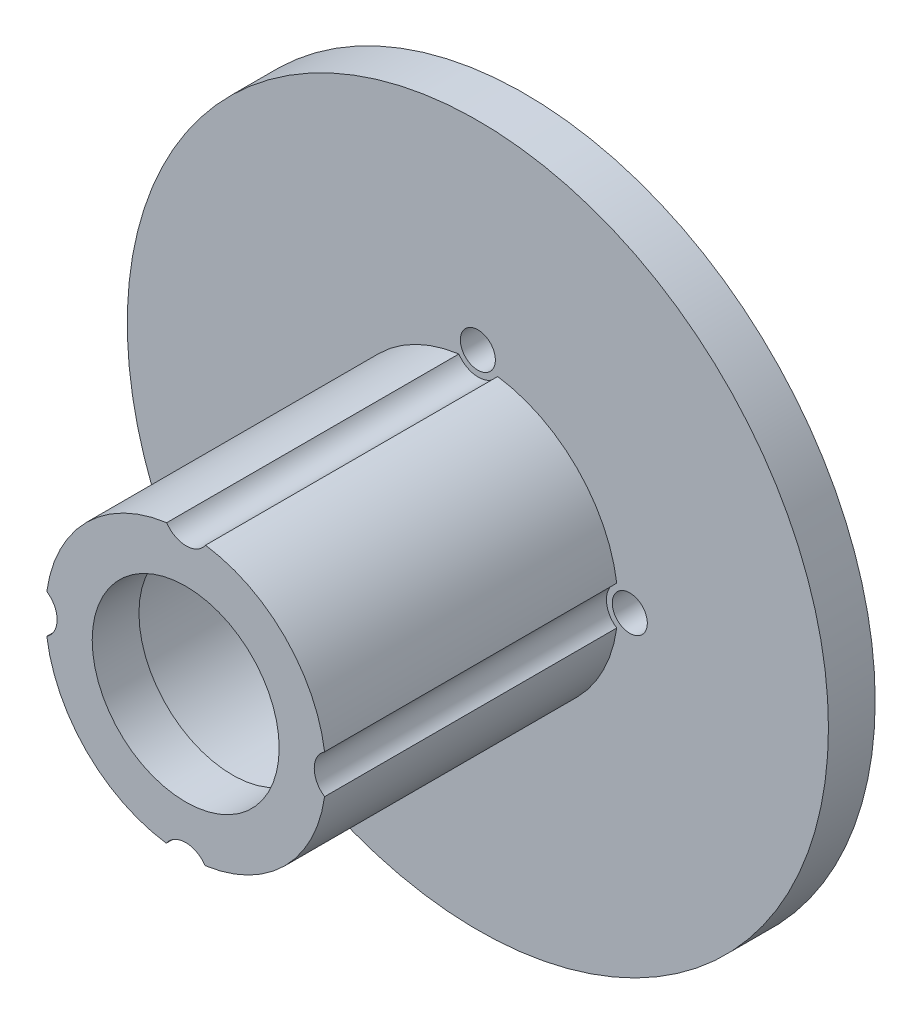
from build123d import *

# Parameters (mm, degrees)
SKETCH2_R           = 30
BOSS_EXTRUDE1_DEPTH = 4
SKETCH3_R           = 12
BOSS_EXTRUDE2_DEPTH = 25
SKETCH4_R           = 9.5
CUT_EXTRUDE1_DEPTH  = 25
SKETCH5_R           = 8
CUT_EXTRUDE2_DEPTH  = 20
SKETCH6_R           = 1.5
CUT_EXTRUDE10_DEPTH = 4
SKETCH8_R           = 2
CUT_EXTRUDE14_DEPTH = 25


with BuildPart() as part:
    # Sketch2 → Boss-Extrude1 (new body)
    with BuildSketch(Plane.XY):
        Circle(SKETCH2_R)
    extrude(amount=BOSS_EXTRUDE1_DEPTH)

    # Sketch3 → Boss-Extrude2 (add)
    with BuildSketch(Plane.XY.offset(4)):
        Circle(SKETCH3_R)
    extrude(amount=BOSS_EXTRUDE2_DEPTH)

    # Sketch4 → Cut-Extrude1 (cut)
    with BuildSketch(Plane(origin=(0, 0, 0), x_dir=(-1, 0, 0), z_dir=(0, 0, -1))):
        Circle(SKETCH4_R)
    extrude(amount=-CUT_EXTRUDE1_DEPTH, mode=Mode.SUBTRACT)

    # Sketch5 → Cut-Extrude2 (cut)
    with BuildSketch(Plane(origin=(0, 0, 25), x_dir=(-1, 0, 0), z_dir=(0, 0, -1))):
        Circle(SKETCH5_R)
    extrude(amount=-CUT_EXTRUDE2_DEPTH, mode=Mode.SUBTRACT)

    # Sketch6 → Cut-Extrude10 (cut)
    with BuildSketch(Plane(origin=(0, 0, 0), x_dir=(-1, 0, 0), z_dir=(0, 0, -1))):
        with Locations((0, 13)):
            Circle(SKETCH6_R)
        with Locations((13, 0)):
            Circle(SKETCH6_R)
        with Locations((0, -13)):
            Circle(SKETCH6_R)
        with Locations((-13, 0)):
            Circle(SKETCH6_R)
    extrude(amount=-CUT_EXTRUDE10_DEPTH, mode=Mode.SUBTRACT)

    # Sketch8 → Cut-Extrude14 (cut)
    with BuildSketch(Plane.XY.offset(29)):
        with Locations((0.039889562, 13)):
            Circle(SKETCH8_R)
        with Locations((0, -13)):
            Circle(SKETCH8_R)
        with Locations((13, 0)):
            Circle(SKETCH8_R)
        with Locations((-13, 0)):
            Circle(SKETCH8_R)
    extrude(amount=-CUT_EXTRUDE14_DEPTH, mode=Mode.SUBTRACT)


solid = part.part
